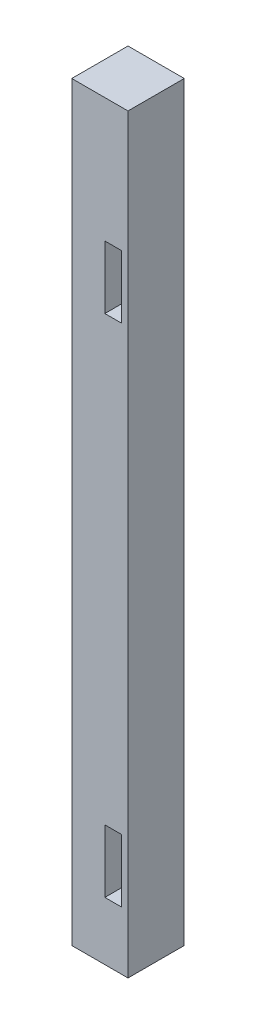
from build123d import *

# Parameters (mm, degrees)
SKETCH1_W           = 8.5
SKETCH1_H           = 8.5
BOSS_EXTRUDE1_DEPTH = 113.5
SKETCH2_W           = 2.5
SKETCH2_H           = 9.5
CUT_EXTRUDE1_DEPTH  = 5
SKETCH3_W           = 2.5
SKETCH3_H           = 9.5
CUT_EXTRUDE2_DEPTH  = 5


with BuildPart() as part:
    # Sketch1 → Boss-Extrude1 (new body)
    with BuildSketch(Plane(origin=(0, 0, 0), x_dir=(1, 0, 0), z_dir=(0, 1, 0))):
        Rectangle(SKETCH1_W, SKETCH1_H)
    extrude(amount=BOSS_EXTRUDE1_DEPTH)

    # Sketch2 → Cut-Extrude1 (cut)
    with BuildSketch(Plane.XY.offset(4.25)):
        with Locations((2, 13.55)):
            Rectangle(SKETCH2_W, SKETCH2_H)
        with Locations((2, 89.98)):
            Rectangle(SKETCH2_W, SKETCH2_H)
    extrude(amount=-CUT_EXTRUDE1_DEPTH, mode=Mode.SUBTRACT)

    # Sketch3 → Cut-Extrude2 (cut)
    with BuildSketch(Plane.ZY.offset(4.25)):
        with Locations((-2, 99.95)):
            Rectangle(SKETCH3_W, SKETCH3_H)
        with Locations((-2, 23.52)):
            Rectangle(SKETCH3_W, SKETCH3_H)
    extrude(amount=-CUT_EXTRUDE2_DEPTH, mode=Mode.SUBTRACT)


solid = part.part
